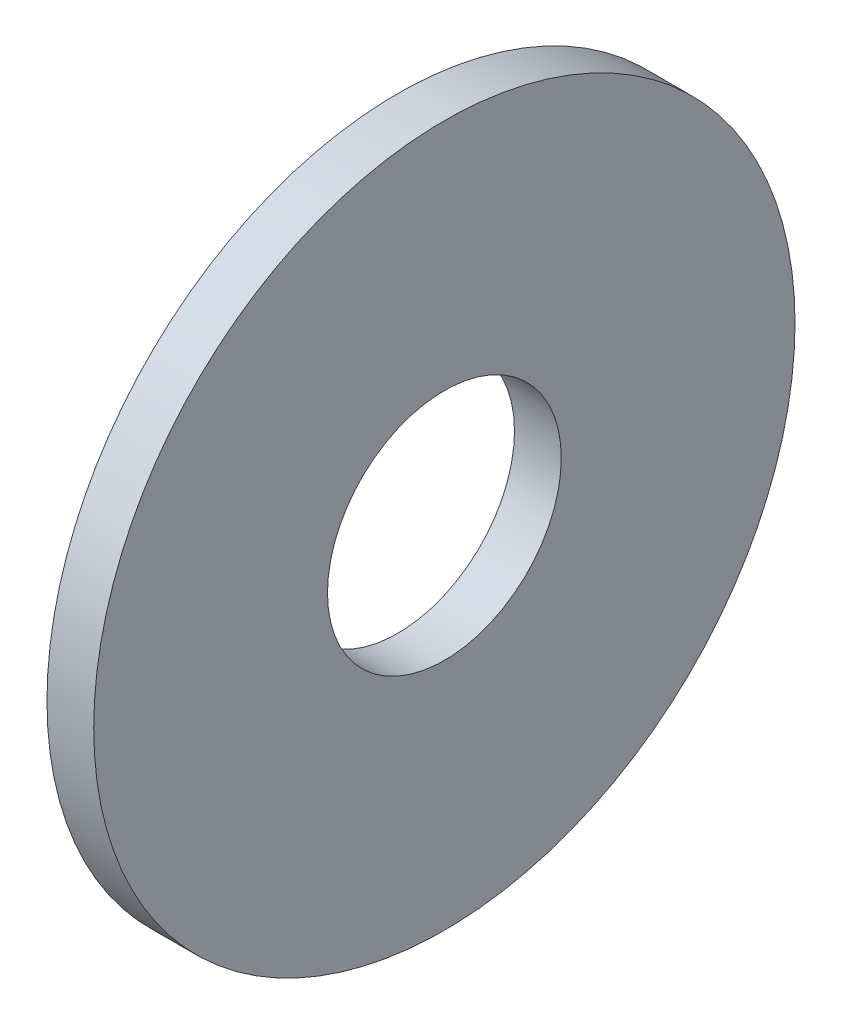
from build123d import *

# Parameters (mm, degrees)
SKETCH1_R           = 7.5
SKETCH1_R_2         = 2.5
BOSS_EXTRUDE1_DEPTH = 1


with BuildPart() as part:
    # Sketch1 → Boss-Extrude1 (new body)
    with BuildSketch(Plane(origin=(0, 0, 0), x_dir=(0, 0, -1), z_dir=(1, 0, 0))):
        Circle(SKETCH1_R)
        Circle(SKETCH1_R_2, mode=Mode.SUBTRACT)
    extrude(amount=BOSS_EXTRUDE1_DEPTH)


solid = part.part
